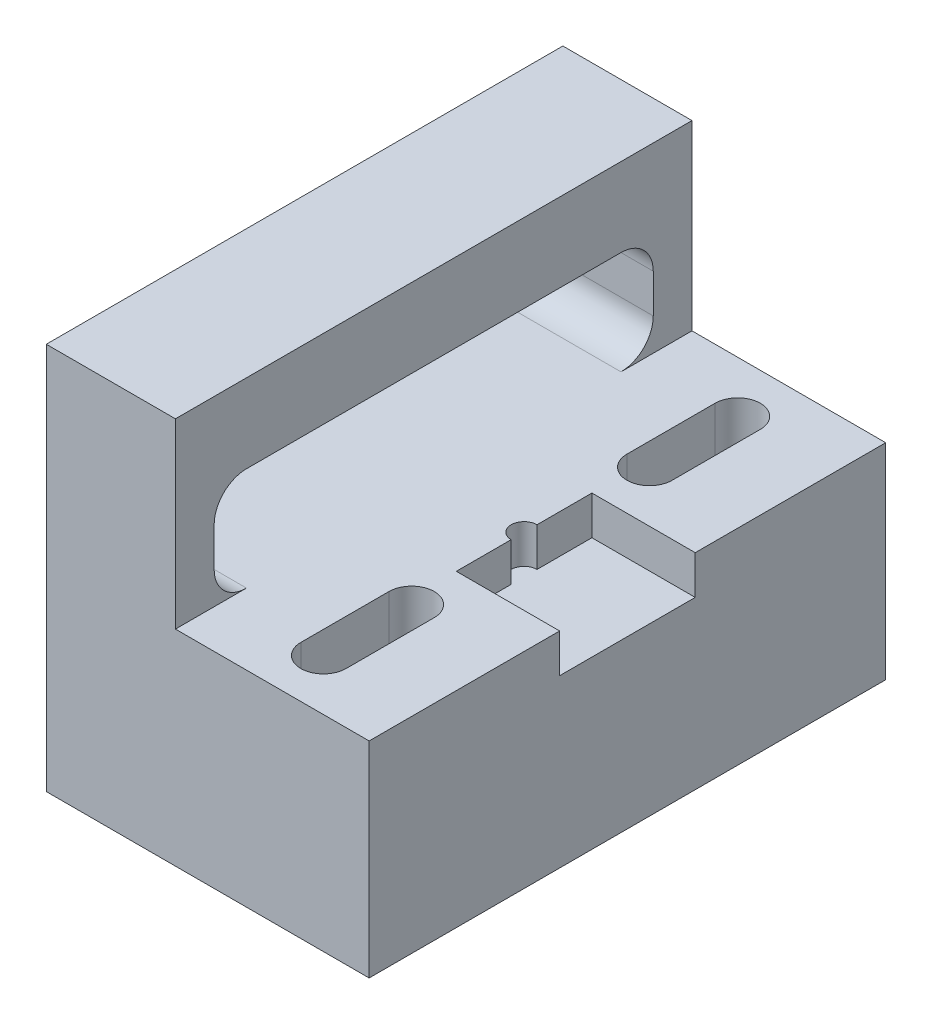
from build123d import *

# Parameters (mm, degrees)
SKETCH1_W                                     = 40
SKETCH1_H                                     = 30
BOSS_EXTRUDE1_DEPTH                           = 10
SKETCH2_W                                     = 4.5
SKETCH2_H                                     = 8
CUT_EXTRUDE1_DEPTH                            = 1
CUT_EXTRUDE2_DEPTH                            = 11
SKETCH4_W                                     = 40
SKETCH4_H                                     = 15.897693
BOSS_EXTRUDE3_DEPTH                           = 15
FIX_DISTANCES_CONVEX_LENS_SEAT_DEPTH          = 3
CHOOSE_SCREW_SIZE_USE_TIGHT_TOLERANCE_C_DEPTH = 16.897693


with BuildPart() as part:
    # Sketch1 → Boss-Extrude1 (new body)
    with BuildSketch(Plane(origin=(0, 0, 0), x_dir=(0, 0, -1), z_dir=(1, 0, 0))):
        with Locations((3.569892473, -6.978494624)):
            Rectangle(SKETCH1_W, SKETCH1_H)
    extrude(amount=BOSS_EXTRUDE1_DEPTH)

    # Sketch2 → Cut-Extrude1 (cut)
    with BuildSketch(Plane.ZY):
        with BuildLine():
            Line((-5.319892473, 2.419198376), (-1.819892473, 2.419198376))
            ThreePointArc((-1.819892473, 2.419198376), (-1.466339083, 2.272751767), (-1.319892473, 1.919198376))
            Line((-1.319892473, 1.919198376), (-5.819892473, 1.919198376))
            ThreePointArc((-5.819892473, 1.919198376), (-5.673445864, 2.272751767), (-5.319892473, 2.419198376))
        make_face()
        with BuildLine():
            Line((-5.319892473, -6.580801624), (-1.819892473, -6.580801624))
            ThreePointArc((-1.819892473, -6.580801624), (-1.466339083, -6.434355014), (-1.319892473, -6.080801624))
            Line((-1.319892473, -6.080801624), (-5.819892473, -6.080801624))
            ThreePointArc((-5.819892473, -6.080801624), (-5.673445864, -6.434355014), (-5.319892473, -6.580801624))
        make_face()
        with Locations((-3.569892473, -2.080801624)):
            Rectangle(SKETCH2_W, SKETCH2_H)
        with BuildLine():
            ThreePointArc((-2.569892473, 2.419198376), (-3.569892473, 3.419198376), (-4.569892473, 2.419198376))
            Line((-4.569892473, 2.419198376), (-2.569892473, 2.419198376))
        make_face()
        with BuildLine():
            Line((-2.569892473, -6.580801624), (-4.569892473, -6.580801624))
            ThreePointArc((-4.569892473, -6.580801624), (-3.569892473, -7.580801624), (-2.569892473, -6.580801624))
        make_face()
    extrude(amount=-CUT_EXTRUDE1_DEPTH, mode=Mode.SUBTRACT)

    # Sketch3 → Cut-Extrude2 (cut, through all)
    with BuildSketch(Plane.ZY):
        with BuildLine():
            Line((-18.069892473, 1.919198376), (10.930107527, 1.919198376))
            ThreePointArc((10.930107527, 1.919198376), (12.69787448, 1.186965329), (13.430107527, -0.580801624))
            Line((13.430107527, -0.580801624), (13.430107527, -3.580801624))
            ThreePointArc((13.430107527, -3.580801624), (12.69787448, -5.348568577), (10.930107527, -6.080801624))
            Line((10.930107527, -6.080801624), (-18.069892473, -6.080801624))
            ThreePointArc((-18.069892473, -6.080801624), (-19.837659426, -5.348568577), (-20.569892473, -3.580801624))
            Line((-20.569892473, -3.580801624), (-20.569892473, -0.580801624))
            ThreePointArc((-20.569892473, -0.580801624), (-19.837659426, 1.186965329), (-18.069892473, 1.919198376))
        make_face()
    extrude(amount=-CUT_EXTRUDE2_DEPTH, mode=Mode.SUBTRACT)

    # Sketch4 → Boss-Extrude3 (add)
    with BuildSketch(Plane(origin=(10, 0, 0), x_dir=(0, 0, -1), z_dir=(1, 0, 0))):
        with Locations((3.569892473, -14.029648124)):
            Rectangle(SKETCH4_W, SKETCH4_H)
    extrude(amount=BOSS_EXTRUDE3_DEPTH)

    # Sketch6 → [fix distances] convex_lens_seat (cut)
    with BuildSketch(Plane(origin=(0, -6.080801624, 0), x_dir=(1, 0, 0), z_dir=(0, 1, 0))):
        Polygon((17, 2.569892473), (17, -1.680107527), (25, -1.680107527), (25, 8.819892473), (17, 8.819892473), (17, 4.569892473), align=None)
        with BuildLine():
            ThreePointArc((17, 4.569892473), (16, 3.569892473), (17, 2.569892473))
            Line((17, 2.569892473), (17, 4.569892473))
        make_face()
    extrude(amount=-FIX_DISTANCES_CONVEX_LENS_SEAT_DEPTH, mode=Mode.SUBTRACT)

    # Sketch7 → [choose screw size, use tight tolerance clearance diameter ] slots (cut, through all)
    with BuildSketch(Plane(origin=(0, -6.080801624, 0), x_dir=(1, 0, 0), z_dir=(0, 1, 0))):
        with BuildLine():
            Line((15.746714751, 12.781776292), (15.746714751, 19.608008654))
            ThreePointArc((15.746714751, 19.608008654), (17.5, 21.361293903), (19.253285249, 19.608008654))
            Line((19.253285249, 19.608008654), (19.253285249, 12.781776292))
            ThreePointArc((19.253285249, 12.781776292), (17.5, 11.028491043), (15.746714751, 12.781776292))
        make_face()
        with BuildLine():
            Line((15.746714751, -5.641991346), (15.746714751, -12.468223708))
            ThreePointArc((15.746714751, -12.468223708), (17.5, -14.221508957), (19.253285249, -12.468223708))
            Line((19.253285249, -12.468223708), (19.253285249, -5.641991346))
            ThreePointArc((19.253285249, -5.641991346), (17.5, -3.888706097), (15.746714751, -5.641991346))
        make_face()
    extrude(amount=-CHOOSE_SCREW_SIZE_USE_TIGHT_TOLERANCE_C_DEPTH, mode=Mode.SUBTRACT)


solid = part.part
